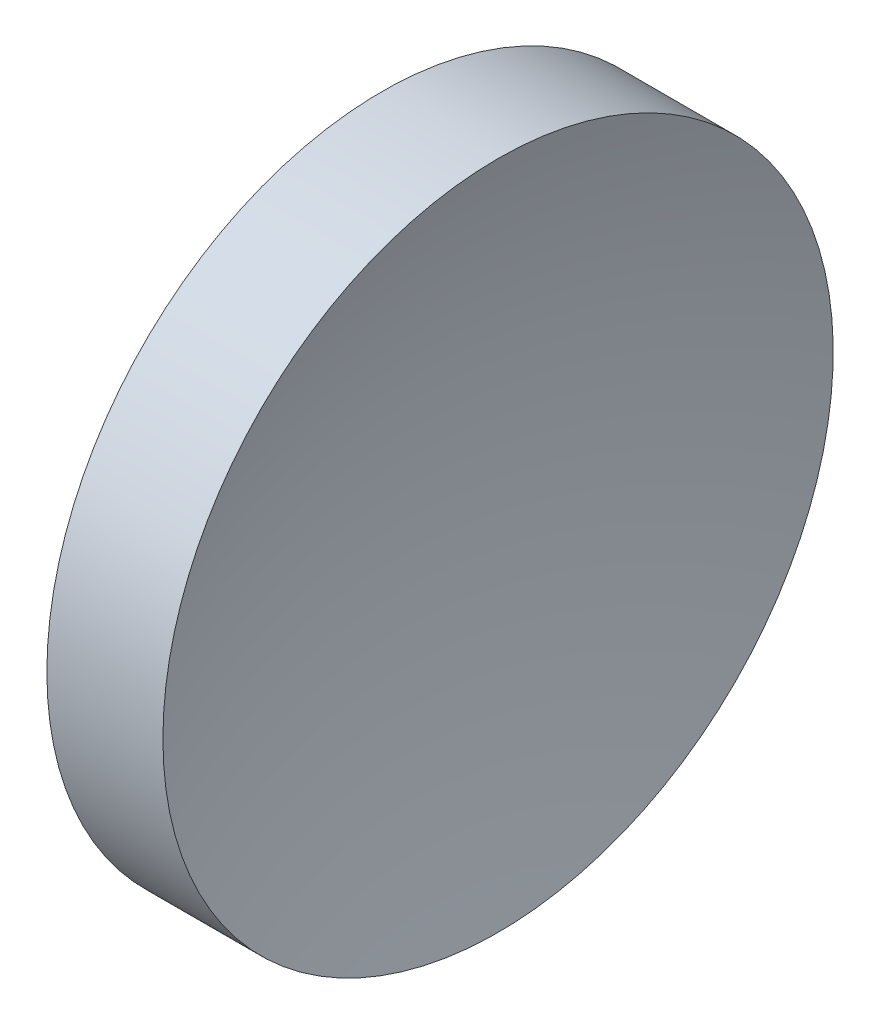
from build123d import *


with BuildPart() as part:
    # 草图1 → 旋转1 (revolve)
    with BuildSketch(Plane.XY):
        with BuildLine():
            Line((44.319152693, 26.089041149), (44.319152693, 34.089041149))
            Line((44.319152693, 34.089041149), (47.088731661, 34.089041149))
            ThreePointArc((47.088731661, 34.089041149), (46.138521202, 30.139097637), (45.819152903, 26.089041149))
            Line((45.819152903, 26.089041149), (44.319152693, 26.089041149))
        make_face()
    revolve(axis=Axis((42.449861114, 26.089041149, 0), (1, 0, 0)))


solid = part.part
